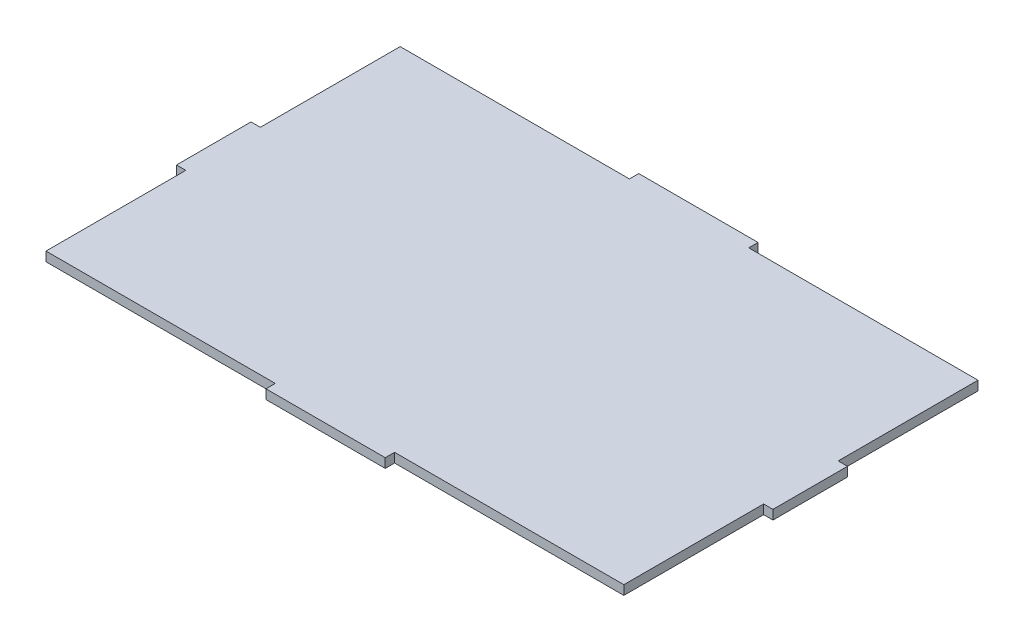
from build123d import *

# Parameters (mm, degrees)
SKETCH1_W           = 203.2
SKETCH1_H           = 127
BOSS_EXTRUDE1_DEPTH = 3.175
CUT_EXTRUDE1_DEPTH  = 3.175


with BuildPart() as part:
    # Sketch1 → Boss-Extrude1 (new body)
    with BuildSketch(Plane(origin=(0, 0, 0), x_dir=(1, 0, 0), z_dir=(0, 1, 0))):
        Rectangle(SKETCH1_W, SKETCH1_H)
    extrude(amount=BOSS_EXTRUDE1_DEPTH)

    # Sketch3 → Cut-Extrude1 (cut)
    with BuildSketch(Plane(origin=(0, 3.175, 0), x_dir=(1, 0, 0), z_dir=(0, 1, 0))):
        Polygon((-98.425, 12.7), (-101.6, 12.7), (-101.6, 63.5), (-20.32, 63.5), (-20.32, 60.325), (-98.425, 60.325), align=None)
        Polygon((20.32, 60.325), (98.425, 60.325), (98.425, 12.7), (101.6, 12.7), (101.6, 63.5), (20.32, 63.5), align=None)
        Polygon((-101.6, -12.7), (-101.6, -65.513366778), (-20.32, -63.5), (-20.32, -60.325), (-98.425, -60.325), (-98.425, -12.7), align=None)
        Polygon((20.32, -60.325), (20.32, -63.5), (101.6, -63.5), (101.6, -12.7), (98.425, -12.7), (98.425, -60.325), align=None)
    extrude(amount=-CUT_EXTRUDE1_DEPTH, mode=Mode.SUBTRACT)


solid = part.part
